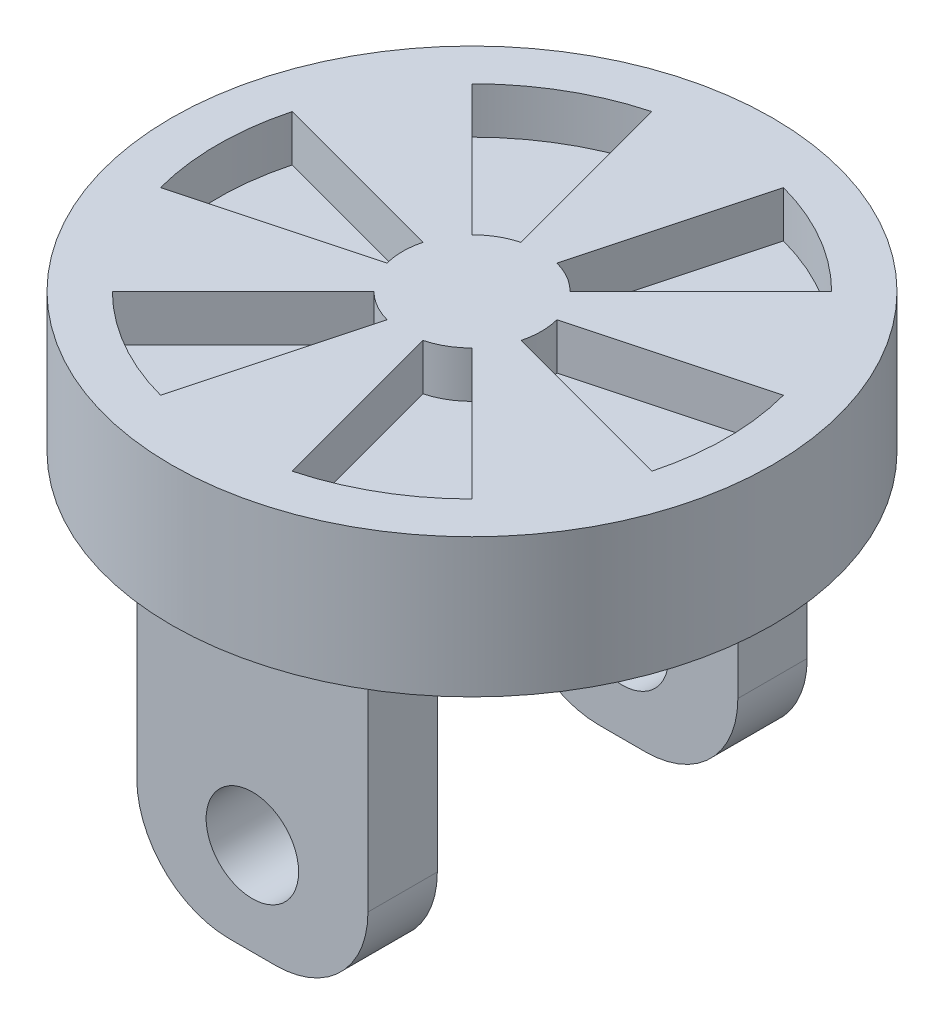
from build123d import *

# Parameters (mm, degrees)
SKETCH_1_R          = 65
EXTRUDE_1_DEPTH     = 30
SKETCH_2_W          = 50
SKETCH_2_H          = 15
EXTRUDE_2_DEPTH     = 70
FILLET_2_R          = 20
SKETCH_3_R          = 10
CUT_EXTRUDE_1_DEPTH = 113.5
CUT_EXTRUDE_2_DEPTH = 10


with BuildPart() as part:
    # 草图1 → 凸台-拉伸1 (new body)
    with BuildSketch(Plane(origin=(0, 0, 0), x_dir=(1, 0, 0), z_dir=(0, 1, 0))):
        Circle(SKETCH_1_R)
    extrude(amount=EXTRUDE_1_DEPTH)

    # 草图2 → 凸台-拉伸2 (add)
    with BuildSketch(Plane.XZ):
        with Locations((0, 40)):
            Rectangle(SKETCH_2_W, SKETCH_2_H)
        with Locations((0, -40)):
            Rectangle(SKETCH_2_W, SKETCH_2_H)
    extrude(amount=EXTRUDE_2_DEPTH)

    # 圆角2
    fillet_2_edges = [part.edges().sort_by_distance(p)[0] for p in [
        (25, -70, 40),
        (-25, -70, 40),
        (-25, -70, -40),
        (25, -70, -40),
    ]]
    fillet(fillet_2_edges, radius=FILLET_2_R)

    # 草图3 → 切除-拉伸1 (cut, through all)
    with BuildSketch(Plane.XY.offset(47.5)):
        with Locations((0, -50)):
            Circle(SKETCH_3_R)
    extrude(amount=-CUT_EXTRUDE_1_DEPTH, mode=Mode.SUBTRACT)

    # 草图7 → 切除-拉伸2 (cut)
    with BuildSketch(Plane(origin=(0, 30, 0), x_dir=(1, 0, 0), z_dir=(0, 1, 0))):
        with BuildLine():
            Line((14.488887394, 3.882285677), (53.125920446, 14.235047481))
            ThreePointArc((53.125920446, 14.235047481), (55, 0), (53.125920446, -14.235047481))
            Line((53.125920446, -14.235047481), (14.488887394, -3.882285677))
            ThreePointArc((14.488887394, -3.882285677), (15, 0), (14.488887394, 3.882285677))
        make_face()
        with BuildLine():
            Line((10.606601718, -10.606601718), (38.890872965, -38.890872965))
            ThreePointArc((38.890872965, -38.890872965), (27.5, -47.631397208), (14.235047481, -53.125920446))
            Line((14.235047481, -53.125920446), (3.882285677, -14.488887394))
            ThreePointArc((3.882285677, -14.488887394), (7.5, -12.990381057), (10.606601718, -10.606601718))
        make_face()
        with BuildLine():
            Line((-3.882285677, -14.488887394), (-14.235047481, -53.125920446))
            ThreePointArc((-14.235047481, -53.125920446), (-27.5, -47.631397208), (-38.890872965, -38.890872965))
            Line((-38.890872965, -38.890872965), (-10.606601718, -10.606601718))
            ThreePointArc((-10.606601718, -10.606601718), (-7.5, -12.990381057), (-3.882285677, -14.488887394))
        make_face()
        with BuildLine():
            Line((-14.488887394, -3.882285677), (-53.125920446, -14.235047481))
            ThreePointArc((-53.125920446, -14.235047481), (-55, 0), (-53.125920446, 14.235047481))
            Line((-53.125920446, 14.235047481), (-14.488887394, 3.882285677))
            ThreePointArc((-14.488887394, 3.882285677), (-15, 0), (-14.488887394, -3.882285677))
        make_face()
        with BuildLine():
            Line((-10.606601718, 10.606601718), (-38.890872965, 38.890872965))
            ThreePointArc((-38.890872965, 38.890872965), (-27.5, 47.631397208), (-14.235047481, 53.125920446))
            Line((-14.235047481, 53.125920446), (-3.882285677, 14.488887394))
            ThreePointArc((-3.882285677, 14.488887394), (-7.5, 12.990381057), (-10.606601718, 10.606601718))
        make_face()
        with BuildLine():
            Line((3.882285677, 14.488887394), (14.235047481, 53.125920446))
            ThreePointArc((14.235047481, 53.125920446), (27.5, 47.631397208), (38.890872965, 38.890872965))
            Line((38.890872965, 38.890872965), (10.606601718, 10.606601718))
            ThreePointArc((10.606601718, 10.606601718), (7.5, 12.990381057), (3.882285677, 14.488887394))
        make_face()
    extrude(amount=-CUT_EXTRUDE_2_DEPTH, mode=Mode.SUBTRACT)


solid = part.part
